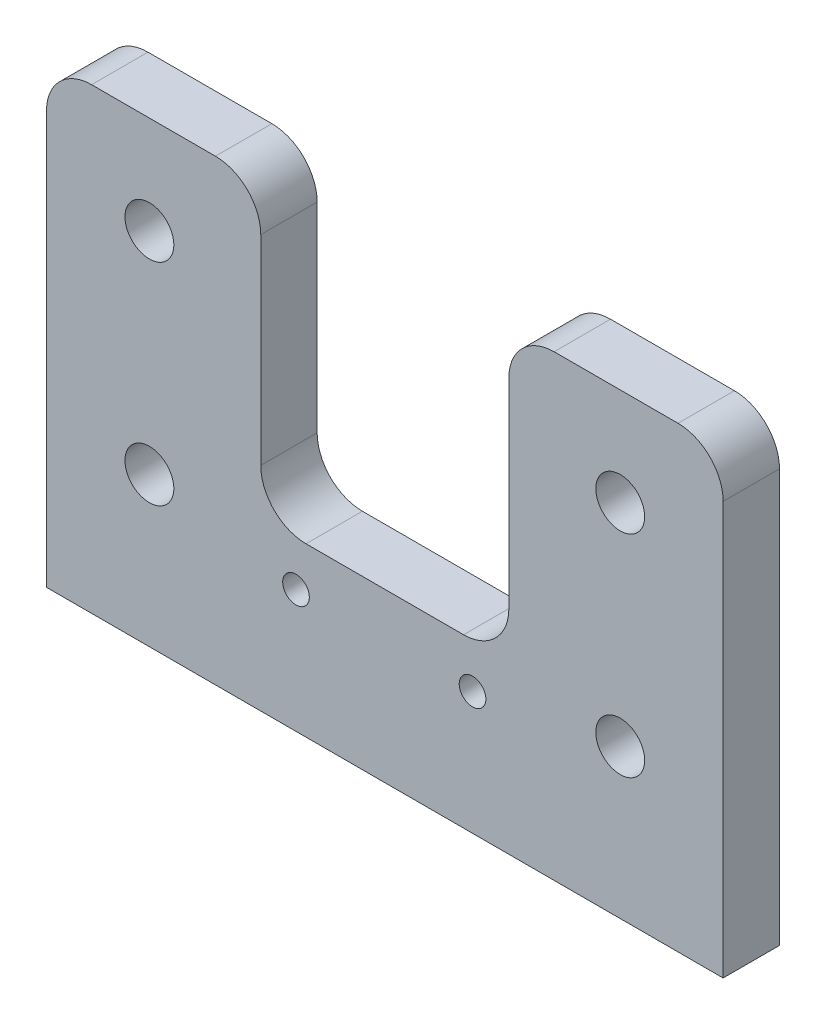
from build123d import *

# Parameters (mm, degrees)
SKETCH1_W           = 76.2
SKETCH1_H           = 51.562
BOSS_EXTRUDE1_DEPTH = 6.35
SKETCH2_W           = 27.94
SKETCH2_H           = 12.7
CUT_EXTRUDE1_DEPTH  = 9.906
FILLET1_R           = 5.08
SKETCH7_R           = 2.75
CUT_EXTRUDE2_DEPTH  = 127
CUT_EXTRUDE4_DEPTH  = 32.416
SKETCH9_W           = 27.94
SKETCH9_H           = 20
CUT_EXTRUDE5_DEPTH  = 18.7
FILLET2_R           = 5.1
SKETCH10_R          = 1.5
CUT_EXTRUDE6_DEPTH  = 10


with BuildPart() as part:
    # Sketch1 → Boss-Extrude1 (new body)
    with BuildSketch(Plane.XY):
        with Locations((38.1, 25.781)):
            Rectangle(SKETCH1_W, SKETCH1_H)
    extrude(amount=BOSS_EXTRUDE1_DEPTH)

    # Sketch2 → Cut-Extrude1 (cut)
    with BuildSketch(Plane.XY.offset(6.35)):
        with Locations((38.1, 45.212)):
            Rectangle(SKETCH2_W, SKETCH2_H)
    extrude(amount=-CUT_EXTRUDE1_DEPTH, mode=Mode.SUBTRACT)

    # Fillet1
    fillet1_edges = [part.edges().sort_by_distance(p)[0] for p in [
        (0, 51.562, 3.175),
        (76.2, 51.562, 3.175),
    ]]
    fillet(fillet1_edges, radius=FILLET1_R)

    # Sketch7 → Cut-Extrude2 (cut)
    with BuildSketch(Plane(origin=(0, 0, 0), x_dir=(-1, 0, 0), z_dir=(0, 0, -1))):
        with Locations((-11.588, 16.8)):
            Circle(SKETCH7_R)
        with Locations((-64.612, 16.8)):
            Circle(SKETCH7_R)
    extrude(amount=-CUT_EXTRUDE2_DEPTH, mode=Mode.SUBTRACT)

    # Sketch8 → Cut-Extrude4 (cut)
    with BuildSketch(Plane.XY.offset(6.35)):
        with BuildLine():
            ThreePointArc((64.612, 43.312), (61.862, 40.562), (64.612, 37.812))
            Line((64.612, 37.812), (64.612, 40.562))
            Line((64.612, 40.562), (64.612, 43.312))
        make_face()
        with BuildLine():
            Line((64.612, 40.562), (64.612, 37.812))
            ThreePointArc((64.612, 37.812), (66.556543648, 38.617456352), (67.362, 40.562))
            ThreePointArc((67.362, 40.562), (66.556543648, 42.506543648), (64.612, 43.312))
            Line((64.612, 43.312), (64.612, 40.562))
        make_face()
    cut_extrude4 = extrude(amount=-CUT_EXTRUDE4_DEPTH, mode=Mode.SUBTRACT)

    # Mirror2: Cut-Extrude4 across plane
    add(cut_extrude4.mirror(Plane.ZY.offset(-38.1)), mode=Mode.SUBTRACT)

    # Sketch9 → Cut-Extrude5 (cut)
    with BuildSketch(Plane.XY.offset(6.35)):
        with Locations((38.1, 28.862)):
            Rectangle(SKETCH9_W, SKETCH9_H)
    extrude(amount=-CUT_EXTRUDE5_DEPTH, mode=Mode.SUBTRACT)

    # Fillet2
    fillet2_edges = [part.edges().sort_by_distance(p)[0] for p in [
        (52.07, 51.562, 3.175),
        (24.13, 51.562, 3.175),
        (52.07, 18.862, 3.175),
        (24.13, 18.862, 3.175),
    ]]
    fillet(fillet2_edges, radius=FILLET2_R)

    # Sketch10 → Cut-Extrude6 (cut)
    with BuildSketch(Plane.XY.offset(6.35)):
        with Locations((47.98, 13.83)):
            Circle(SKETCH10_R)
        with Locations((28.1, 13.83)):
            Circle(SKETCH10_R)
    extrude(amount=-CUT_EXTRUDE6_DEPTH, mode=Mode.SUBTRACT)


solid = part.part
